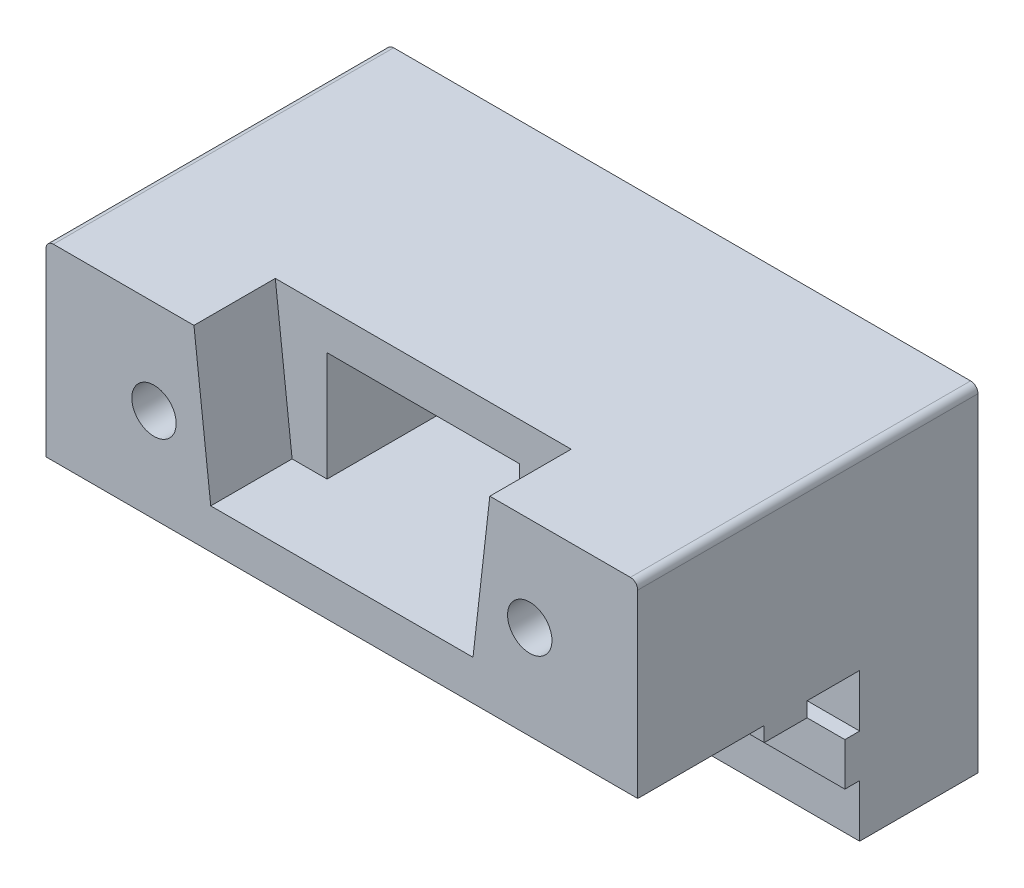
from build123d import *

# Parameters (mm, degrees)
ESQUISSE1_W              = 40
ESQUISSE1_H              = 12.7
BOSS_EXTRU_1_DEPTH       = 23
CONG_1_R                 = 0.5
ESQUISSE2_R              = 1.5
ENL_V_MAT_EXTRU_1_DEPTH  = 24
ENL_V_MAT_EXTRU_2_DEPTH  = 5.5
ESQUISSE5_W              = 13
ESQUISSE5_H              = 8
ENL_V_MAT_EXTRU_3_DEPTH  = 18.5
BOSS_EXTRU_8_DEPTH       = 40
ESQUISSE16_R             = 4
ENL_V_MAT_EXTRU_10_DEPTH = 13
ESQUISSE18_R             = 4
ENL_V_MAT_EXTRU_11_DEPTH = 5
ESQUISSE19_R             = 1.5
ENL_V_MAT_EXTRU_12_DEPTH = 19


with BuildPart() as part:
    # Esquisse1 → Boss.-Extru.1 (new body)
    with BuildSketch(Plane.XY):
        Rectangle(ESQUISSE1_W, ESQUISSE1_H)
    extrude(amount=BOSS_EXTRU_1_DEPTH)

    # Congé1
    cong_1_edges = [part.edges().sort_by_distance(p)[0] for p in [
        (-20, 6.35, 11.5),
        (20, 6.35, 11.5),
    ]]
    fillet(cong_1_edges, radius=CONG_1_R)

    # Esquisse2 → Enlèv. mat.-Extru.1 (cut, through all)
    with BuildSketch(Plane.XY.offset(23)):
        with Locations((-12.7, 0)):
            Circle(ESQUISSE2_R)
        with Locations((12.7, 0)):
            Circle(ESQUISSE2_R)
    extrude(amount=-ENL_V_MAT_EXTRU_1_DEPTH, mode=Mode.SUBTRACT)

    # Esquisse4 → Enlèv. mat.-Extru.2 (cut)
    with BuildSketch(Plane(origin=(0, 0, 23), x_dir=(-1, 0, 0), z_dir=(0, 0, -1))):
        Polygon((-10, 6.35), (10, 6.35), (8.5, -6.85), (-8.5, -6.85), align=None)
    extrude(amount=ENL_V_MAT_EXTRU_2_DEPTH, mode=Mode.SUBTRACT)

    # Esquisse5 → Enlèv. mat.-Extru.3 (cut, through all)
    with BuildSketch(Plane.XY.offset(17.5)):
        with Locations((0, -0.25)):
            Rectangle(ESQUISSE5_W, ESQUISSE5_H)
    extrude(amount=-ENL_V_MAT_EXTRU_3_DEPTH, mode=Mode.SUBTRACT)

    # Esquisse17 → Boss.-Extru.8 (add)
    with BuildSketch(Plane.ZY.offset(20)):
        Polygon((8, -16.35), (0, -16.35), (0, -3.65), (23, -3.65), (23, -6.35), (14.45, -6.35), (14.45, -7.35), (11.55, -7.35), (11.55, -6.35), (8, -6.35), (8, -9.9), (9, -9.9), (9, -12.8), (8, -12.8), align=None)
    extrude(amount=-BOSS_EXTRU_8_DEPTH)

    # Esquisse16 → Enlèv. mat.-Extru.10 (cut)
    with BuildSketch(Plane(origin=(0, 0, 0), x_dir=(-1, 0, 0), z_dir=(0, 0, -1))):
        with Locations((-12.7, 0)):
            Circle(ESQUISSE16_R)
        with Locations((12.7, 0)):
            Circle(ESQUISSE16_R)
    extrude(amount=-ENL_V_MAT_EXTRU_10_DEPTH, mode=Mode.SUBTRACT)

    # Esquisse18 → Enlèv. mat.-Extru.11 (cut)
    with BuildSketch(Plane(origin=(0, 0, 0), x_dir=(-1, 0, 0), z_dir=(0, 0, -1))):
        with Locations((0, -11.35)):
            Circle(ESQUISSE18_R)
    extrude(amount=-ENL_V_MAT_EXTRU_11_DEPTH, mode=Mode.SUBTRACT)

    # Esquisse19 → Enlèv. mat.-Extru.12 (cut, through all)
    with BuildSketch(Plane(origin=(0, 0, 5), x_dir=(-1, 0, 0), z_dir=(0, 0, -1))):
        with Locations((0, -11.35)):
            Circle(ESQUISSE19_R)
    extrude(amount=-ENL_V_MAT_EXTRU_12_DEPTH, mode=Mode.SUBTRACT)


solid = part.part
